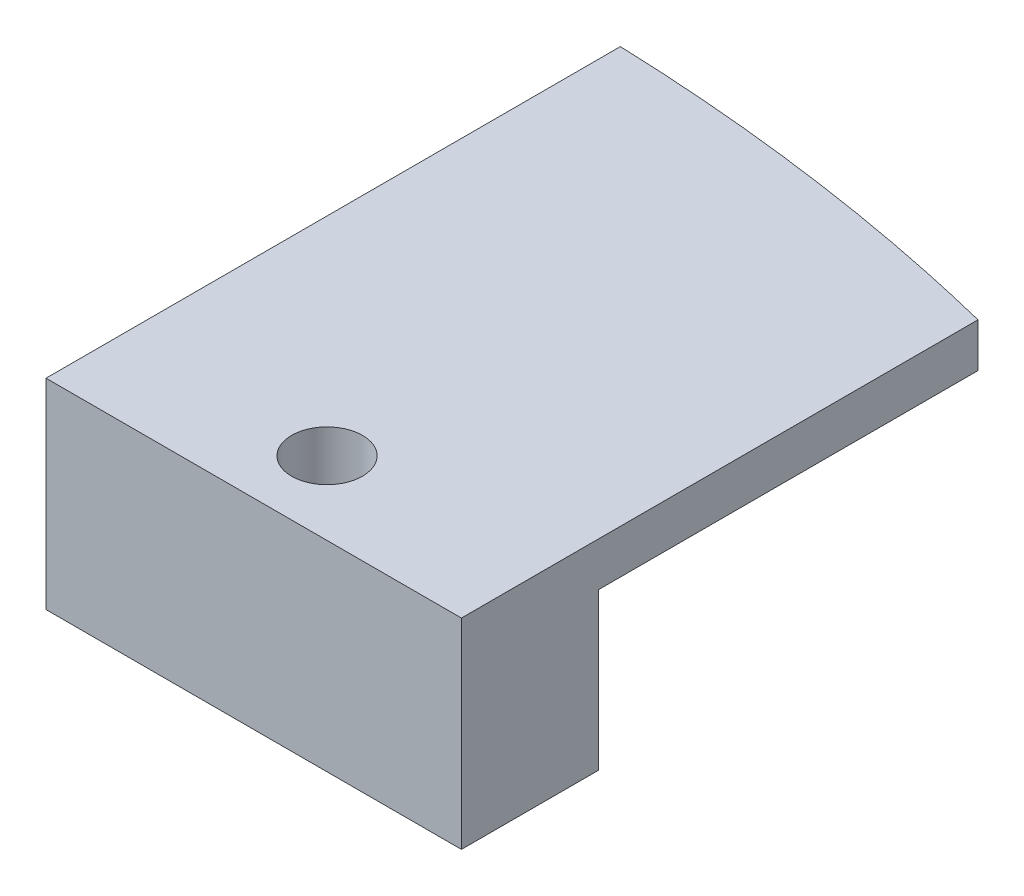
from build123d import *

# Parameters (mm, degrees)
BOSS_EXTRUDE1_DEPTH = 1.8
CUT_EXTRUDE2_REACH  = 3.8
BOSS_EXTRUDE2_DEPTH = 1.8
BOSS_EXTRUDE3_DEPTH = 6.4
CUT_EXTRUDE3_REACH  = 10.2
SKETCH7_R           = 1.45


with BuildPart() as part:
    # Sketch1 → Boss-Extrude1 (new body)
    with BuildSketch(Plane(origin=(0, 0, 0), x_dir=(1, 0, 0), z_dir=(0, 1, 0))):
        Polygon((0, 15), (0, 0), (17, 0), (17, 10), align=None)
    extrude(amount=BOSS_EXTRUDE1_DEPTH)

    # Sketch3 → Cut-Extrude2 (cut, up to next)
    with BuildSketch(Plane(origin=(0, 1.8, 0), x_dir=(1, 0, 0), z_dir=(0, 1, 0)), mode=Mode.PRIVATE) as cut_extrude2_sk1:
        with BuildLine():
            Line((0, 15), (0, 5.504405832))
            add(Edge.make_bspline(
                [(17, 3.138617849), (8.707332044, 5.198817795), (0, 5.504405832)],
                knots=[4.238740022, 4.238740022, 4.238740022, 4.471680234, 4.471680234, 4.471680234], degree=2, weights=[1, 0.993225021, 1]))
            Line((17, 3.138617849), (17, 10))
            Line((17, 10), (0, 15))
        make_face()
    cut_extrude2_tool1 = extrude(cut_extrude2_sk1.sketch, amount=-CUT_EXTRUDE2_REACH, mode=Mode.PRIVATE) & part.part
    add(cut_extrude2_tool1.solids().sort_by_distance((8.024676, 1.8, -8.663074))[0], mode=Mode.SUBTRACT)

    # Sketch5 → Boss-Extrude2 (add)
    with BuildSketch(Plane(origin=(0, 1.8, 0), x_dir=(1, 0, 0), z_dir=(0, 1, 0))):
        Polygon((17, 0), (17, -18), (2.5e-08, -18), (0, 0), align=None)
    extrude(amount=-BOSS_EXTRUDE2_DEPTH)

    # Sketch6 → Boss-Extrude3 (add)
    with BuildSketch(Plane.XZ):
        Polygon((2.5e-08, 18), (17, 18), (17, 12.4), (1.9e-08, 12.4), align=None)
    extrude(amount=BOSS_EXTRUDE3_DEPTH)

    # Sketch7 → Cut-Extrude3 (cut, up to next)
    with BuildSketch(Plane(origin=(0, 1.8, 0), x_dir=(1, 0, 0), z_dir=(0, 1, 0)), mode=Mode.PRIVATE) as cut_extrude3_sk1:
        with Locations(Location((8.500000012, -15, 0), (0, 0, 270))):  # turned: the seam where the file's is
            Circle(SKETCH7_R)
    cut_extrude3_tool1 = extrude(cut_extrude3_sk1.sketch, amount=-CUT_EXTRUDE3_REACH, mode=Mode.PRIVATE) & part.part
    add(cut_extrude3_tool1.solids().sort_by_distance((8.5, 1.8, 15))[0], mode=Mode.SUBTRACT)


solid = part.part
